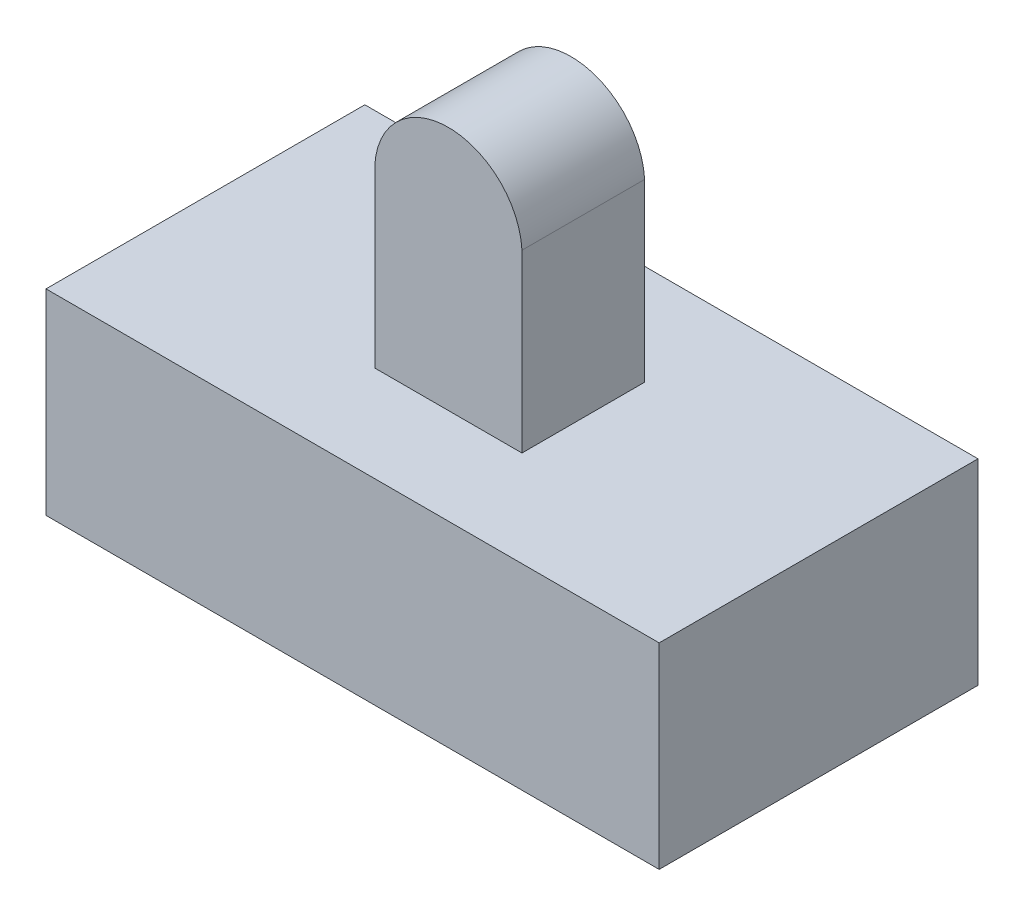
from build123d import *

# Parameters (mm, degrees)
SKETCH3_W           = 25
SKETCH3_H           = 13
BOSS_EXTRUDE1_DEPTH = 8
SKETCH4_W           = 6
SKETCH4_H           = 4.2
CUT_EXTRUDE1_DEPTH  = 7
SKETCH5_W           = 6
SKETCH5_H           = 5
BOSS_EXTRUDE2_DEPTH = 10
CUT_EXTRUDE2_DEPTH  = 10


with BuildPart() as part:
    # Sketch3 → Boss-Extrude1 (new body)
    with BuildSketch(Plane(origin=(0, 0, 0), x_dir=(1, 0, 0), z_dir=(0, 1, 0))):
        with Locations((6.675257732, -1.809278351)):
            Rectangle(SKETCH3_W, SKETCH3_H)
    extrude(amount=BOSS_EXTRUDE1_DEPTH)

    # Sketch4 → Cut-Extrude1 (cut)
    with BuildSketch(Plane.XZ):
        with Locations((6.568666205, 2.102026057)):
            Rectangle(SKETCH4_W, SKETCH4_H)
    extrude(amount=-CUT_EXTRUDE1_DEPTH, mode=Mode.SUBTRACT)

    # Sketch5 → Boss-Extrude2 (add)
    with BuildSketch(Plane(origin=(0, 8, 0), x_dir=(1, 0, 0), z_dir=(0, 1, 0))):
        with Locations((6.675257732, -1.902518117)):
            Rectangle(SKETCH5_W, SKETCH5_H)
    extrude(amount=BOSS_EXTRUDE2_DEPTH)

    # Sketch6 → Cut-Extrude2 (cut)
    with BuildSketch(Plane(origin=(0, 0, -0.597481883), x_dir=(-1, 0, 0), z_dir=(0, 0, -1))):
        with BuildLine():
            Line((-3.675257732, 18), (-6.675257732, 18))
            ThreePointArc((-6.675257732, 18), (-4.610198245, 17.177859086), (-3.675257732, 15.161358998))
            Line((-3.675257732, 15.161358998), (-3.675257732, 18))
        make_face()
        with BuildLine():
            Line((-9.675257732, 18), (-9.675257732, 15.161358998))
            ThreePointArc((-9.675257732, 15.161358998), (-8.740317219, 17.177859086), (-6.675257732, 18))
            Line((-6.675257732, 18), (-9.675257732, 18))
        make_face()
    extrude(amount=-CUT_EXTRUDE2_DEPTH, mode=Mode.SUBTRACT)


solid = part.part
